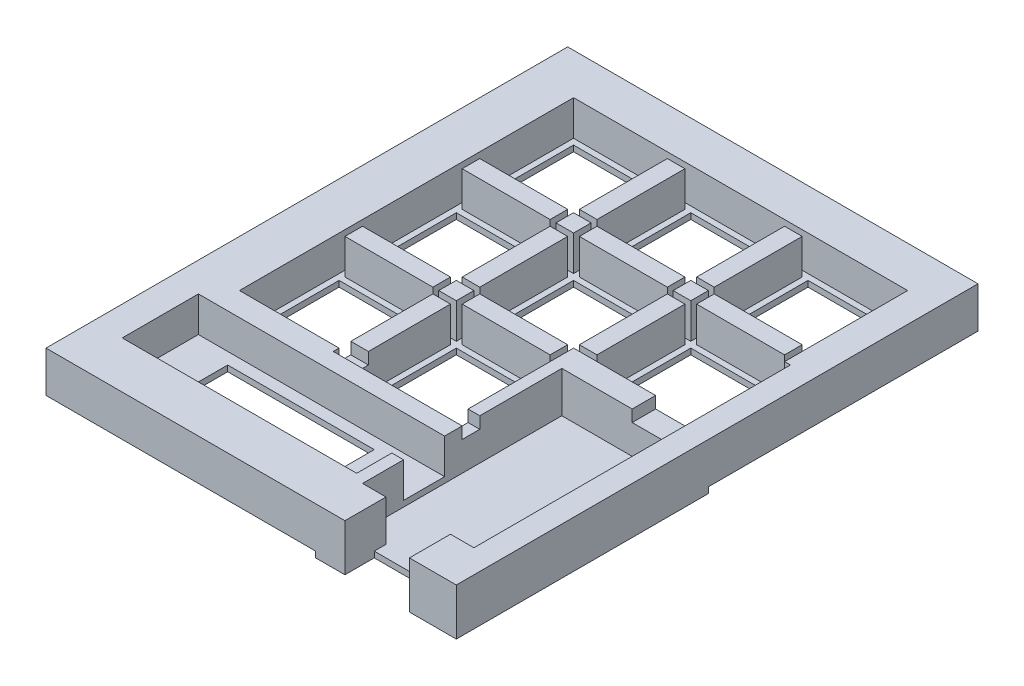
from build123d import *

# Parameters (mm, degrees)
SKETCH_1_W                = 71
SKETCH_1_H                = 67
EXTRUDE_2_DEPTH           = 5
SKETCH_1_2_W              = 71
SKETCH_1_2_H              = 67
EXTRUDE_3_DEPTH           = 7
SKETCH_9_W                = 20
SKETCH_9_H                = 20
CUT_EXTRUDE_5_DEPTH       = 36
SKETCH_10_W               = 15
SKETCH_10_H               = 15
SKETCH_10_W_2             = 1
SKETCH_10_H_2             = 20
CUT_EXTRUDE_6_DEPTH       = 32
SKETCH_14_W               = 1
SKETCH_14_H               = 37
SKETCH_14_H_2             = 57
CUT_EXTRUDE_7_DEPTH       = 19
SKETCH_15_W               = 37
SKETCH_15_H               = 1
SKETCH_15_W_2             = 57
CUT_EXTRUDE_8_DEPTH       = 27
SKETCH_16_W               = 23
SKETCH_16_H               = 21
CUT_EXTRUDE_9_DEPTH       = 17
SKETCH_17_W               = 1
SKETCH_17_H               = 67
CUT_EXTRUDE_10_DEPTH      = 27
SKETCH_18_W               = 1
SKETCH_18_H               = 19
CUT_EXTRUDE_11_DEPTH      = 1
SKETCH_19_W               = 2
SKETCH_19_H               = 19
CUT_EXTRUDE_12_DEPTH      = 1
SKETCH_20_W               = 1
SKETCH_20_H               = 3
CUT_EXTRUDE_13_DEPTH      = 1
SKETCH_21_W               = 2
SKETCH_21_H               = 1
CUT_EXTRUDE_15_DEPTH      = 1
SKETCH_22_W               = 23
SKETCH_22_H               = 1
EXTRUDE_4_DEPTH           = 7
SKETCH_23_W               = 1
SKETCH_23_H               = 1
SKETCH_23_W_2             = 2
CUT_EXTRUDE_16_DEPTH      = 1
SKETCH_24_W               = 70
SKETCH_24_H               = 1
EXTRUDE_5_DEPTH           = 7
SKETCH_27_W               = 5
SKETCH_27_H               = 20
EXTRUDE_6_DEPTH           = 7
SKETCH_28_W               = 42
SKETCH_28_H               = 8
EXTRUDE_7_DEPTH           = 7
SKETCH_29_W               = 42
SKETCH_29_H               = 1
CUT_EXTRUDE_17_DEPTH      = 7
SKETCH_30_W               = 47
SKETCH_30_H               = 1
EXTRUDE_8_DEPTH           = 7
SKETCH_31_W               = 2
SKETCH_31_H               = 3
EXTRUDE_9_DEPTH           = 7
SKETCH_32_W               = 4
SKETCH_32_H               = 41
EXTRUDE_11_DEPTH          = 7
SKETCH_33_W               = 4
SKETCH_33_H               = 4
EXTRUDE_12_DEPTH          = 7
SKETCH_34_W               = 4
SKETCH_34_H               = 4
EXTRUDE_13_DEPTH          = 7
SKETCH_35_W               = 19
SKETCH_35_H               = 3
EXTRUDE_14_DEPTH          = 7
SKETCH_36_W               = 11
SKETCH_36_H               = 3
CUT_EXTRUDE_20_DEPTH      = 7
SKETCH_37_R               = 0.5
CUT_EXTRUDE_22_DEPTH      = 9
SKETCH_38_R               = 1
CUT_EXTRUDE_23_DEPTH      = 5
EXTRUDE_15_DEPTH          = 1
SKETCH_37_3_R             = 0.5
CUT_EXTRUDE_26_DEPTH      = 12
CUT_EXTRUDE_26_DEPTH_BACK = 12
SKETCH_40_W               = 2
SKETCH_40_H               = 1
CUT_EXTRUDE_28_DEPTH      = 9
CUT_EXTRUDE_28_DEPTH_BACK = 1
SKETCH_42_W               = 3
SKETCH_42_H               = 4
CUT_EXTRUDE_29_DEPTH      = 1
SKETCH_43_W               = 3
SKETCH_43_H               = 15
SKETCH_43_W_2             = 15
SKETCH_43_H_2             = 3
EXTRUDE_17_DEPTH          = 1
SKETCH_44_W               = 2
SKETCH_44_H               = 3.001760435
EXTRUDE_18_DEPTH          = 8
SKETCH_45_W               = 7
SKETCH_45_H               = 13
EXTRUDE_19_DEPTH          = 1
SKETCH_46_W               = 10
SKETCH_46_H               = 13
EXTRUDE_20_DEPTH          = 1
SKETCH_49_W               = 22.379206011
SKETCH_49_H               = 34.512992384
EXTRUDE_26_DEPTH          = 1
SKETCH_50_W               = 4.314622461
SKETCH_50_H               = 5.170850193
SKETCH_50_W_2             = 4.148439206
SKETCH_50_H_2             = 6.322894144
SKETCH_50_W_3             = 5.848573563
EXTRUDE_27_DEPTH          = 8
SKETCH_51_W               = 4
SKETCH_51_H               = 18
SKETCH_51_W_2             = 1
EXTRUDE_28_DEPTH          = 1
SKETCH_52_W               = 11
SKETCH_52_H               = 2
EXTRUDE_29_DEPTH          = 1
EXTRUDE_30_DEPTH          = 1
SKETCH_55_W               = 15
SKETCH_55_H               = 15
CUT_EXTRUDE_31_DEPTH      = 1
CUT_EXTRUDE_32_DEPTH      = 1
SKETCH_57_W               = 46
SKETCH_57_H               = 23
CUT_EXTRUDE_33_DEPTH      = 1
SKETCH_58_W               = 15
SKETCH_58_H               = 3
EXTRUDE_31_DEPTH          = 1
SKETCH_59_W               = 22
SKETCH_59_H               = 1
CUT_EXTRUDE_37_DEPTH      = 2
CUT_EXTRUDE_37_DEPTH_BACK = 1
SKETCH_60_W               = 25
SKETCH_60_H               = 2
SKETCH_60_H_2             = 1
EXTRUDE_32_DEPTH          = 1
SKETCH_61_W               = 2
SKETCH_61_H               = 4
CUT_EXTRUDE_39_DEPTH      = 1
CUT_EXTRUDE_39_DEPTH_BACK = 1
SKETCH_62_W               = 3
SKETCH_62_H               = 1
CUT_EXTRUDE_40_DEPTH      = 1
CUT_EXTRUDE_40_DEPTH_BACK = 1


with BuildPart() as part:
    # Sketch 1 → Extrude 2 (new body)
    with BuildSketch(Plane(origin=(0, 0, 0), x_dir=(1, 0, 0), z_dir=(0, 1, 0))):
        with Locations((35.5, 33.5)):
            Rectangle(SKETCH_1_W, SKETCH_1_H)
    extrude(amount=EXTRUDE_2_DEPTH)

    # Sketch 1_2 → Extrude 3 (add)
    with BuildSketch(Plane(origin=(0, 0, 0), x_dir=(1, 0, 0), z_dir=(0, 1, 0))):
        with Locations((35.5, 33.5)):
            Rectangle(SKETCH_1_2_W, SKETCH_1_2_H)
    extrude(amount=EXTRUDE_3_DEPTH)

    # Sketch 9 → Cut-Extrude 5 (cut)
    with BuildSketch(Plane(origin=(0, 0, 0), x_dir=(1, 0, 0), z_dir=(0, 1, 0))):
        with Locations((61, 10)):
            Rectangle(SKETCH_9_W, SKETCH_9_H)
    extrude(amount=CUT_EXTRUDE_5_DEPTH, mode=Mode.SUBTRACT)

    # Sketch 10 → Cut-Extrude 6 (cut)
    with BuildSketch(Plane(origin=(0, 0, 0), x_dir=(1, 0, 0), z_dir=(0, 1, 0))):
        with Locations((17.5, 52.5)):
            Rectangle(SKETCH_10_W, SKETCH_10_H)
        with Locations((37.5, 52.5)):
            Rectangle(SKETCH_10_W, SKETCH_10_H)
        with Locations((57.5, 52.5)):
            Rectangle(SKETCH_10_W, SKETCH_10_H)
        with Locations((57.5, 32.5)):
            Rectangle(SKETCH_10_W, SKETCH_10_H)
        with Locations((37.5, 32.5)):
            Rectangle(SKETCH_10_W, SKETCH_10_H)
        with Locations((17.5, 32.5)):
            Rectangle(SKETCH_10_W, SKETCH_10_H)
        with Locations((17.5, 12.5)):
            Rectangle(SKETCH_10_W, SKETCH_10_H)
        with Locations((37.5, 12.5)):
            Rectangle(SKETCH_10_W, SKETCH_10_H)
        with Locations((50.5, 10)):
            Rectangle(SKETCH_10_W_2, SKETCH_10_H_2)
    extrude(amount=CUT_EXTRUDE_6_DEPTH, mode=Mode.SUBTRACT)

    # Sketch 14 → Cut-Extrude 7 (cut)
    with BuildSketch(Plane(origin=(0, 1, 0), x_dir=(1, 0, 0), z_dir=(0, 1, 0))):
        with Locations((65.5, 42.5)):
            Rectangle(SKETCH_14_W, SKETCH_14_H)
        with Locations((49.5, 42.5)):
            Rectangle(SKETCH_14_W, SKETCH_14_H)
        with Locations((29.5, 32.5)):
            Rectangle(SKETCH_14_W, SKETCH_14_H_2)
        with Locations((25.5, 32.5)):
            Rectangle(SKETCH_14_W, SKETCH_14_H_2)
        with Locations((9.5, 32.5)):
            Rectangle(SKETCH_14_W, SKETCH_14_H_2)
        with Locations((45.5, 32.5)):
            Rectangle(SKETCH_14_W, SKETCH_14_H_2)
    extrude(amount=CUT_EXTRUDE_7_DEPTH, mode=Mode.SUBTRACT)

    # Sketch 15 → Cut-Extrude 8 (cut)
    with BuildSketch(Plane(origin=(0, 1, 0), x_dir=(1, 0, 0), z_dir=(0, 1, 0))):
        with Locations((27.5, 4.5)):
            Rectangle(SKETCH_15_W, SKETCH_15_H)
        with Locations((37.5, 24.5)):
            Rectangle(SKETCH_15_W_2, SKETCH_15_H)
        with Locations((37.5, 44.5)):
            Rectangle(SKETCH_15_W_2, SKETCH_15_H)
        with Locations((27.5, 20.5)):
            Rectangle(SKETCH_15_W, SKETCH_15_H)
        with Locations((37.5, 40.5)):
            Rectangle(SKETCH_15_W_2, SKETCH_15_H)
        with Locations((37.5, 60.5)):
            Rectangle(SKETCH_15_W_2, SKETCH_15_H)
    extrude(amount=CUT_EXTRUDE_8_DEPTH, mode=Mode.SUBTRACT)

    # Sketch 16 → Cut-Extrude 9 (cut)
    with BuildSketch(Plane(origin=(0, 0, 0), x_dir=(1, 0, 0), z_dir=(0, 1, 0))):
        with Locations((59.5, 10.5)):
            Rectangle(SKETCH_16_W, SKETCH_16_H)
    extrude(amount=CUT_EXTRUDE_9_DEPTH, mode=Mode.SUBTRACT)

    # Sketch 17 → Cut-Extrude 10 (cut)
    with BuildSketch(Plane(origin=(0, 0, 0), x_dir=(1, 0, 0), z_dir=(0, 1, 0))):
        with Locations((0.5, 33.5)):
            Rectangle(SKETCH_17_W, SKETCH_17_H)
    extrude(amount=CUT_EXTRUDE_10_DEPTH, mode=Mode.SUBTRACT)

    # Sketch 18 → Cut-Extrude 11 (cut)
    with BuildSketch(Plane(origin=(0, 7, 0), x_dir=(1, 0, 0), z_dir=(0, 1, 0))):
        with Locations((66.5, 30.5)):
            Rectangle(SKETCH_18_W, SKETCH_18_H)
    extrude(amount=-CUT_EXTRUDE_11_DEPTH, mode=Mode.SUBTRACT)

    # Sketch 19 → Cut-Extrude 12 (cut)
    with BuildSketch(Plane(origin=(0, 7, 0), x_dir=(1, 0, 0), z_dir=(0, 1, 0))):
        with Locations((66, 30.5)):
            Rectangle(SKETCH_19_W, SKETCH_19_H)
    extrude(amount=-CUT_EXTRUDE_12_DEPTH, mode=Mode.SUBTRACT)

    # Sketch 20 → Cut-Extrude 13 (cut)
    with BuildSketch(Plane(origin=(0, 7, 0), x_dir=(1, 0, 0), z_dir=(0, 1, 0))):
        with Locations((63.5, 22.5)):
            Rectangle(SKETCH_20_W, SKETCH_20_H)
    extrude(amount=-CUT_EXTRUDE_13_DEPTH, mode=Mode.SUBTRACT)

    # Sketch 21 → Cut-Extrude 15 (cut)
    with BuildSketch(Plane(origin=(0, 7, 0), x_dir=(1, 0, 0), z_dir=(0, 1, 0))):
        with Locations((47, 5.5)):
            Rectangle(SKETCH_21_W, SKETCH_21_H)
    extrude(amount=-CUT_EXTRUDE_15_DEPTH, mode=Mode.SUBTRACT)

    # Sketch 22 → Extrude 4 (add)
    with BuildSketch(Plane(origin=(0, 7, 0), x_dir=(1, 0, 0), z_dir=(0, 1, 0))):
        with Locations((59.5, 20.5)):
            Rectangle(SKETCH_22_W, SKETCH_22_H)
    extrude(amount=-EXTRUDE_4_DEPTH)

    # Sketch 23 → Cut-Extrude 16 (cut)
    with BuildSketch(Plane(origin=(0, 7, 0), x_dir=(1, 0, 0), z_dir=(0, 1, 0))):
        with Locations((63.5, 20.5)):
            Rectangle(SKETCH_23_W, SKETCH_23_H)
        with Locations((66, 20.5)):
            Rectangle(SKETCH_23_W_2, SKETCH_23_H)
    extrude(amount=-CUT_EXTRUDE_16_DEPTH, mode=Mode.SUBTRACT)

    # Sketch 24 → Extrude 5 (add)
    with BuildSketch(Plane(origin=(0, 7, 0), x_dir=(1, 0, 0), z_dir=(0, 1, 0))):
        with Locations((36, 67.5)):
            Rectangle(SKETCH_24_W, SKETCH_24_H)
    extrude(amount=-EXTRUDE_5_DEPTH)

    # Sketch 27 → Extrude 6 (add)
    with BuildSketch(Plane(origin=(0, 7, 0), x_dir=(1, 0, 0), z_dir=(0, 1, 0))):
        with Locations((3.5, -10)):
            Rectangle(SKETCH_27_W, SKETCH_27_H)
    extrude(amount=-EXTRUDE_6_DEPTH)

    # Sketch 28 → Extrude 7 (add)
    with BuildSketch(Plane(origin=(0, 7, 0), x_dir=(1, 0, 0), z_dir=(0, 1, 0))):
        with Locations((27, -16)):
            Rectangle(SKETCH_28_W, SKETCH_28_H)
    extrude(amount=-EXTRUDE_7_DEPTH)

    # Sketch 29 → Cut-Extrude 17 (cut)
    with BuildSketch(Plane(origin=(0, 7, 0), x_dir=(1, 0, 0), z_dir=(0, 1, 0))):
        with Locations((27, -12.5)):
            Rectangle(SKETCH_29_W, SKETCH_29_H)
    extrude(amount=-CUT_EXTRUDE_17_DEPTH, mode=Mode.SUBTRACT)

    # Sketch 30 → Extrude 8 (add)
    with BuildSketch(Plane(origin=(0, 7, 0), x_dir=(1, 0, 0), z_dir=(0, 1, 0))):
        with Locations((24.5, -20.5)):
            Rectangle(SKETCH_30_W, SKETCH_30_H)
    extrude(amount=-EXTRUDE_8_DEPTH)

    # Sketch 31 → Extrude 9 (add)
    with BuildSketch(Plane(origin=(0, 7, 0), x_dir=(1, 0, 0), z_dir=(0, 1, 0))):
        with Locations((47, -11.5)):
            Rectangle(SKETCH_31_W, SKETCH_31_H)
    extrude(amount=-EXTRUDE_9_DEPTH)

    # Sketch 32 → Extrude 11 (add)
    with BuildSketch(Plane(origin=(0, 7, 0), x_dir=(1, 0, 0), z_dir=(0, 1, 0))):
        with Locations((69, -0.5)):
            Rectangle(SKETCH_32_W, SKETCH_32_H)
    extrude(amount=-EXTRUDE_11_DEPTH)

    # Sketch 33 → Extrude 12 (add)
    with BuildSketch(Plane(origin=(0, 7, 0), x_dir=(1, 0, 0), z_dir=(0, 1, 0))):
        with Locations((65, -19)):
            Rectangle(SKETCH_33_W, SKETCH_33_H)
    extrude(amount=-EXTRUDE_12_DEPTH)

    # Sketch 34 → Extrude 13 (add)
    with BuildSketch(Plane(origin=(0, 7, 0), x_dir=(1, 0, 0), z_dir=(0, 1, 0))):
        with Locations((50, -19)):
            Rectangle(SKETCH_34_W, SKETCH_34_H)
    extrude(amount=-EXTRUDE_13_DEPTH)

    # Sketch 35 → Extrude 14 (add)
    with BuildSketch(Plane(origin=(0, 7, 0), x_dir=(1, 0, 0), z_dir=(0, 1, 0))):
        with Locations((57.5, -15.5)):
            Rectangle(SKETCH_35_W, SKETCH_35_H)
    extrude(amount=-EXTRUDE_14_DEPTH)

    # Sketch 36 → Cut-Extrude 20 (cut)
    with BuildSketch(Plane(origin=(0, 0, 0), x_dir=(1, 0, 0), z_dir=(0, 1, 0))):
        with Locations((57.5, -15.5)):
            Rectangle(SKETCH_36_W, SKETCH_36_H)
    extrude(amount=CUT_EXTRUDE_20_DEPTH, mode=Mode.SUBTRACT)

    # Sketch 37 → Cut-Extrude 22 (cut)
    with BuildSketch(Plane(origin=(0, 7, 0), x_dir=(1, 0, 0), z_dir=(0, 1, 0))):
        with Locations((3, -18)):
            Circle(SKETCH_37_R)
        with Locations((69.5, -18)):
            Circle(SKETCH_37_R)
        with Locations((69.5, 64)):
            Circle(SKETCH_37_R)
        with Locations((3.5, 64)):
            Circle(SKETCH_37_R)
    extrude(amount=-CUT_EXTRUDE_22_DEPTH, mode=Mode.SUBTRACT)

    # Sketch 38 → Cut-Extrude 23 (cut)
    with BuildSketch(Plane(origin=(0, 0, 0), x_dir=(1, 0, 0), z_dir=(0, 1, 0))):
        with Locations((69.5, -18)):
            Circle(SKETCH_38_R)
        with Locations((69.5, 64)):
            Circle(SKETCH_38_R)
        with Locations((3.5, 64)):
            Circle(SKETCH_38_R)
        with Locations((3, -18)):
            Circle(SKETCH_38_R)
    extrude(amount=CUT_EXTRUDE_23_DEPTH, mode=Mode.SUBTRACT)

    # Sketch 39 → Extrude 15 (add)
    with BuildSketch(Plane(origin=(0, 7, 0), x_dir=(1, 0, 0), z_dir=(0, 1, 0))):
        Polygon((1, 68), (71, 68), (71, -21), (63, -21), (63, -14), (67, -14), (67, 40), (66, 40), (66, 61), (9, 61), (9, 4), (46, 4), (46, 5), (48, 5), (48, 0), (6, 0), (6, -13), (46, -13), (46, -10), (48, -10), (48, -14), (52, -14), (52, -21), (1, -21), align=None)
    extrude(amount=EXTRUDE_15_DEPTH)

    # Sketch 37_3 → Cut-Extrude 26 (cut, two sides)
    with BuildSketch(Plane(origin=(0, 7, 0), x_dir=(1, 0, 0), z_dir=(0, 1, 0))) as cut_extrude_26_sk:
        with Locations((3, -18)):
            Circle(SKETCH_37_3_R)
        with Locations((69.5, -18)):
            Circle(SKETCH_37_3_R)
        with Locations((69.5, 64)):
            Circle(SKETCH_37_3_R)
        with Locations((3.5, 64)):
            Circle(SKETCH_37_3_R)
    extrude(amount=CUT_EXTRUDE_26_DEPTH, mode=Mode.SUBTRACT)
    extrude(cut_extrude_26_sk.sketch, amount=-CUT_EXTRUDE_26_DEPTH_BACK, mode=Mode.SUBTRACT)

    # Sketch 40 → Cut-Extrude 28 (cut, two sides)
    with BuildSketch(Plane(origin=(0, 7, 0), x_dir=(1, 0, 0), z_dir=(0, 1, 0))) as cut_extrude_28_sk:
        with Locations((47, 4.5)):
            Rectangle(SKETCH_40_W, SKETCH_40_H)
    extrude(amount=CUT_EXTRUDE_28_DEPTH, mode=Mode.SUBTRACT)
    extrude(cut_extrude_28_sk.sketch, amount=-CUT_EXTRUDE_28_DEPTH_BACK, mode=Mode.SUBTRACT)

    # Sketch 42 → Cut-Extrude 29 (cut)
    with BuildSketch(Plane(origin=(0, 7, 0), x_dir=(1, 0, 0), z_dir=(0, 1, 0))):
        with Locations((63.5, 22)):
            Rectangle(SKETCH_42_W, SKETCH_42_H)
    extrude(amount=-CUT_EXTRUDE_29_DEPTH, mode=Mode.SUBTRACT)

    # Sketch 43 → Extrude 17 (add)
    with BuildSketch(Plane(origin=(0, 7, 0), x_dir=(1, 0, 0), z_dir=(0, 1, 0))):
        Polygon((46, 6), (46, 24), (62, 24), (62, 20), (48, 20), (48, 6), align=None)
        with Locations((47.5, 32.5)):
            Rectangle(SKETCH_43_W, SKETCH_43_H)
        with Locations((47.5, 52.5)):
            Rectangle(SKETCH_43_W, SKETCH_43_H)
        with Locations((57.5, 42.5)):
            Rectangle(SKETCH_43_W_2, SKETCH_43_H_2)
        with Locations((27.5, 52.5)):
            Rectangle(SKETCH_43_W, SKETCH_43_H)
        with Locations((27.5, 32.5)):
            Rectangle(SKETCH_43_W, SKETCH_43_H)
        with Locations((17.5, 42.5)):
            Rectangle(SKETCH_43_W_2, SKETCH_43_H_2)
        with Locations((37.5, 42.5)):
            Rectangle(SKETCH_43_W_2, SKETCH_43_H_2)
        with Locations((17.5, 22.5)):
            Rectangle(SKETCH_43_W_2, SKETCH_43_H_2)
        with Locations((27.5, 12.5)):
            Rectangle(SKETCH_43_W, SKETCH_43_H)
        with Locations((27.5, 22.5)):
            Rectangle(SKETCH_43_W, SKETCH_43_H_2)
        with Locations((47.5, 42.5)):
            Rectangle(SKETCH_43_W, SKETCH_43_H_2)
        with Locations((27.5, 42.5)):
            Rectangle(SKETCH_43_W, SKETCH_43_H_2)
    extrude(amount=EXTRUDE_17_DEPTH)

    # Sketch 44 → Extrude 18 (add)
    with BuildSketch(Plane(origin=(0, 0, 0), x_dir=(1, 0, 0), z_dir=(0, 1, 0))):
        with Locations((47, -8.499119782)):
            Rectangle(SKETCH_44_W, SKETCH_44_H)
    extrude(amount=EXTRUDE_18_DEPTH)

    # Sketch 45 → Extrude 19 (add)
    with BuildSketch(Plane(origin=(0, 1, 0), x_dir=(1, 0, 0), z_dir=(0, 1, 0))):
        with Locations((9.5, -6.5)):
            Rectangle(SKETCH_45_W, SKETCH_45_H)
    extrude(amount=EXTRUDE_19_DEPTH)

    # Sketch 46 → Extrude 20 (add)
    with BuildSketch(Plane(origin=(0, 1, 0), x_dir=(1, 0, 0), z_dir=(0, 1, 0))):
        with Locations((43, -6.5)):
            Rectangle(SKETCH_46_W, SKETCH_46_H)
    extrude(amount=EXTRUDE_20_DEPTH)

    # Sketch 49 → Extrude 26 (add)
    with BuildSketch(Plane(origin=(0, 0, 0), x_dir=(1, 0, 0), z_dir=(0, 1, 0))):
        with Locations((57.189603006, 3.256496192)):
            Rectangle(SKETCH_49_W, SKETCH_49_H)
    extrude(amount=EXTRUDE_26_DEPTH)

    # Sketch 50 → Extrude 27 (add)
    with BuildSketch(Plane(origin=(0, 0, 0), x_dir=(1, 0, 0), z_dir=(0, 1, 0))):
        with Locations((3.15731123, -18.414574904)):
            Rectangle(SKETCH_50_W, SKETCH_50_H)
        with Locations((68.925780397, -18.414574904)):
            Rectangle(SKETCH_50_W_2, SKETCH_50_H)
        with Locations((68.925780397, 64.838552928)):
            Rectangle(SKETCH_50_W_2, SKETCH_50_H_2)
        with Locations((3.924286782, 64.838552928)):
            Rectangle(SKETCH_50_W_3, SKETCH_50_H_2)
    extrude(amount=EXTRUDE_27_DEPTH)

    # Sketch 51 → Extrude 28 (add)
    with BuildSketch(Plane(origin=(0, 1, 0), x_dir=(1, 0, 0), z_dir=(0, 1, 0))):
        with Locations((8, -4)):
            Rectangle(SKETCH_51_W, SKETCH_51_H)
        with Locations((45.5, -4)):
            Rectangle(SKETCH_51_W_2, SKETCH_51_H)
    extrude(amount=-EXTRUDE_28_DEPTH)

    # Sketch 52 → Extrude 29 (add)
    with BuildSketch(Plane(origin=(0, 1, 0), x_dir=(1, 0, 0), z_dir=(0, 1, 0))):
        with Locations((57.5, -15)):
            Rectangle(SKETCH_52_W, SKETCH_52_H)
    extrude(amount=-EXTRUDE_29_DEPTH)

    # Sketch 54 → Extrude 30 (add)
    with BuildSketch(Plane(origin=(0, 1, 0), x_dir=(1, 0, 0), z_dir=(0, 1, 0))):
        Polygon((9, 61), (66, 61), (66, 24), (46, 24), (46, 4), (9, 4), align=None)
    extrude(amount=EXTRUDE_30_DEPTH)

    # Sketch 55 → Cut-Extrude 31 (cut)
    with BuildSketch(Plane(origin=(0, 1, 0), x_dir=(1, 0, 0), z_dir=(0, 1, 0))):
        with Locations((57.5, 52.5)):
            Rectangle(SKETCH_55_W, SKETCH_55_H)
        with Locations((37.5, 52.5)):
            Rectangle(SKETCH_55_W, SKETCH_55_H)
        with Locations((17.5, 52.5)):
            Rectangle(SKETCH_55_W, SKETCH_55_H)
        with Locations((57.5, 32.5)):
            Rectangle(SKETCH_55_W, SKETCH_55_H)
        with Locations((37.5, 32.5)):
            Rectangle(SKETCH_55_W, SKETCH_55_H)
        with Locations((17.5, 32.5)):
            Rectangle(SKETCH_55_W, SKETCH_55_H)
        with Locations((37.5, 12.5)):
            Rectangle(SKETCH_55_W, SKETCH_55_H)
        with Locations((17.5, 12.5)):
            Rectangle(SKETCH_55_W, SKETCH_55_H)
    extrude(amount=CUT_EXTRUDE_31_DEPTH, mode=Mode.SUBTRACT)

    # Sketch 56 → Cut-Extrude 32 (cut)
    with BuildSketch(Plane(origin=(0, 1, 0), x_dir=(1, 0, 0), z_dir=(0, 1, 0))):
        Polygon((1, 68), (1, 2), (47, 2), (47, 22), (71, 22), (71, 68), align=None)
    extrude(amount=-CUT_EXTRUDE_32_DEPTH, mode=Mode.SUBTRACT)

    # Sketch 57 → Cut-Extrude 33 (cut)
    with BuildSketch(Plane(origin=(0, 1, 0), x_dir=(1, 0, 0), z_dir=(0, 1, 0))):
        with Locations((24, -9.5)):
            Rectangle(SKETCH_57_W, SKETCH_57_H)
    extrude(amount=-CUT_EXTRUDE_33_DEPTH, mode=Mode.SUBTRACT)

    # Sketch 58 → Extrude 31 (add)
    with BuildSketch(Plane(origin=(0, 7, 0), x_dir=(1, 0, 0), z_dir=(0, 1, 0))):
        with Locations((37.5, 22.5)):
            Rectangle(SKETCH_58_W, SKETCH_58_H)
    extrude(amount=EXTRUDE_31_DEPTH)

    # Sketch 59 → Cut-Extrude 37 (cut, two sides)
    with BuildSketch(Plane(origin=(0, 7, 0), x_dir=(1, 0, 0), z_dir=(0, 1, 0))) as cut_extrude_37_sk:
        with Locations((37, 3.5)):
            Rectangle(SKETCH_59_W, SKETCH_59_H)
    extrude(amount=CUT_EXTRUDE_37_DEPTH, mode=Mode.SUBTRACT)
    extrude(cut_extrude_37_sk.sketch, amount=-CUT_EXTRUDE_37_DEPTH_BACK, mode=Mode.SUBTRACT)

    # Sketch 60 → Extrude 32 (add)
    with BuildSketch(Plane(origin=(0, 1, 0), x_dir=(1, 0, 0), z_dir=(0, 1, 0))):
        with Locations((25.5, -1)):
            Rectangle(SKETCH_60_W, SKETCH_60_H)
        with Locations((25.5, -12.5)):
            Rectangle(SKETCH_60_W, SKETCH_60_H_2)
    extrude(amount=EXTRUDE_32_DEPTH)

    # Sketch 61 → Cut-Extrude 39 (cut, two sides)
    with BuildSketch(Plane(origin=(0, 7, 0), x_dir=(1, 0, 0), z_dir=(0, 1, 0))) as cut_extrude_39_sk:
        with Locations((61, 22)):
            Rectangle(SKETCH_61_W, SKETCH_61_H)
    extrude(amount=CUT_EXTRUDE_39_DEPTH, mode=Mode.SUBTRACT)
    extrude(cut_extrude_39_sk.sketch, amount=-CUT_EXTRUDE_39_DEPTH_BACK, mode=Mode.SUBTRACT)

    # Sketch 62 → Cut-Extrude 40 (cut, two sides)
    with BuildSketch(Plane(origin=(0, 7, 0), x_dir=(1, 0, 0), z_dir=(0, 1, 0))) as cut_extrude_40_sk:
        with Locations((27.5, 5.5)):
            Rectangle(SKETCH_62_W, SKETCH_62_H)
    extrude(amount=CUT_EXTRUDE_40_DEPTH, mode=Mode.SUBTRACT)
    extrude(cut_extrude_40_sk.sketch, amount=-CUT_EXTRUDE_40_DEPTH_BACK, mode=Mode.SUBTRACT)


solid = part.part
